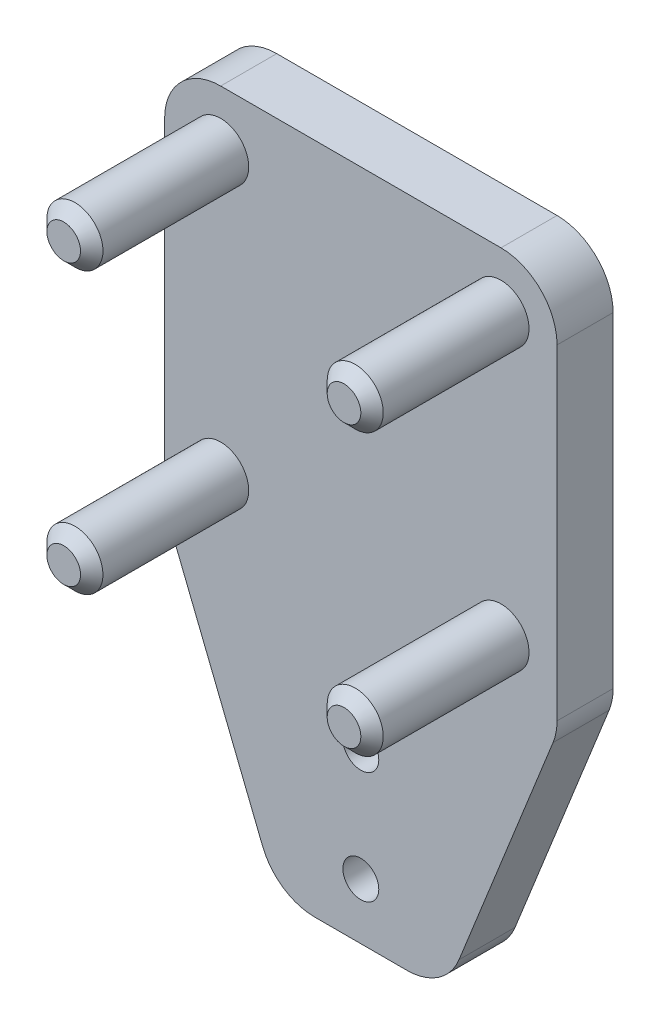
from build123d import *

# Parameters (mm, degrees)
SKETCH1_W           = 35
SKETCH1_H           = 35
BOSS_EXTRUDE1_DEPTH = 5
SKETCH2_R           = 2.5
BOSS_EXTRUDE2_DEPTH = 14
FILLET1_R           = 5
CHAMFER1_SIZE       = 1
BOSS_EXTRUDE3_DEPTH = 5
SKETCH5_R           = 1.6
CUT_EXTRUDE1_DEPTH  = 14
FILLET2_R           = 5


with BuildPart() as part:
    # Sketch1 → Boss-Extrude1 (new body)
    with BuildSketch(Plane.XY):
        with Locations((17.5, -17.5)):
            Rectangle(SKETCH1_W, SKETCH1_H)
    extrude(amount=BOSS_EXTRUDE1_DEPTH)

    # Sketch2 → Boss-Extrude2 (add)
    with BuildSketch(Plane.XY.offset(5)):
        with Locations((5, -5)):
            Circle(SKETCH2_R)
        with Locations((30, -5)):
            Circle(SKETCH2_R)
        with Locations((30, -30)):
            Circle(SKETCH2_R)
        with Locations((5, -30)):
            Circle(SKETCH2_R)
    extrude(amount=BOSS_EXTRUDE2_DEPTH)

    # Fillet1
    fillet1_edges = [part.edges().sort_by_distance(p)[0] for p in [
        (0, 0, 2.5),
        (0, -35, 2.5),
        (35, -35, 2.5),
        (35, 0, 2.5),
    ]]
    fillet(fillet1_edges, radius=FILLET1_R)

    # Chamfer1
    chamfer1_edges = [part.edges().sort_by_distance(p)[0] for p in [
        (2.5, -5, 19),
        (27.5, -5, 19),
        (27.5, -30, 19),
        (2.5, -30, 19),
    ]]
    chamfer(chamfer1_edges, length=CHAMFER1_SIZE)

    # Sketch3 → Boss-Extrude3 (add)
    with BuildSketch(Plane(origin=(0, 0, 0), x_dir=(-1, 0, 0), z_dir=(0, 0, -1))):
        Polygon((-35, -30), (-35, -35), (-25, -60), (-10, -60), (0, -35), (0, -30), align=None)
    extrude(amount=-BOSS_EXTRUDE3_DEPTH)

    # Sketch5 → Cut-Extrude1 (cut)
    with BuildSketch(Plane.XY.offset(5)):
        with Locations((17.5, -55)):
            Circle(SKETCH5_R)
        with Locations((17.5, -45)):
            Circle(SKETCH5_R)
    extrude(amount=-CUT_EXTRUDE1_DEPTH, mode=Mode.SUBTRACT)

    # Fillet2
    fillet2_edges = [part.edges().sort_by_distance(p)[0] for p in [
        (35, -35, 2.5),
        (25, -60, 2.5),
        (10, -60, 2.5),
        (0, -35, 2.5),
    ]]
    fillet(fillet2_edges, radius=FILLET2_R)


solid = part.part
